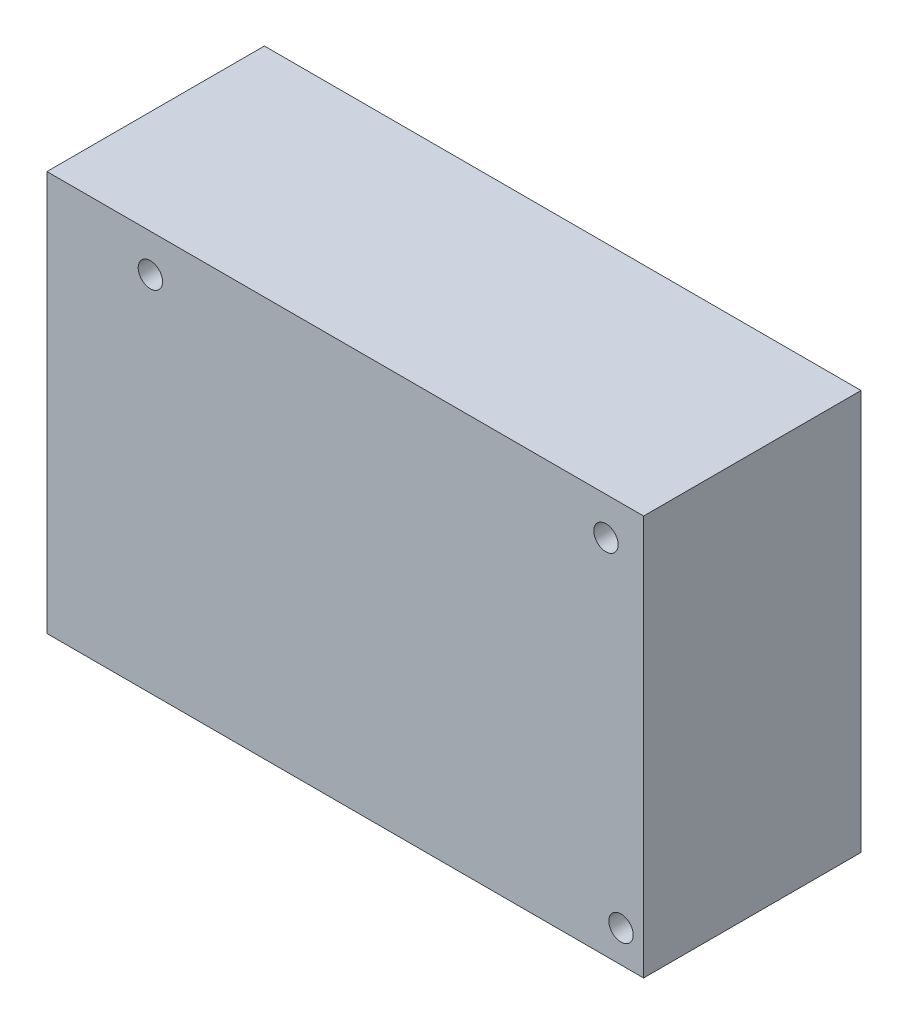
from build123d import *

# Parameters (mm, degrees)
SKETCH1_W           = 87.122
SKETCH1_H           = 58.42
BOSS_EXTRUDE1_DEPTH = 31.75
SKETCH2_R           = 1.778
CUT_EXTRUDE1_DEPTH  = 32.75


with BuildPart() as part:
    # Sketch1 → Boss-Extrude1 (new body)
    with BuildSketch(Plane.XY):
        Rectangle(SKETCH1_W, SKETCH1_H)
    extrude(amount=BOSS_EXTRUDE1_DEPTH)

    # Sketch2 → Cut-Extrude1 (cut, through all)
    with BuildSketch(Plane.XY.offset(31.75)):
        with Locations((-28.4607, 23.7109)):
            Circle(SKETCH2_R)
        with Locations((38.0619, 23.7109)):
            Circle(SKETCH2_R)
        with Locations((40.259, -24.5364)):
            Circle(SKETCH2_R)
    extrude(amount=-CUT_EXTRUDE1_DEPTH, mode=Mode.SUBTRACT)


solid = part.part
